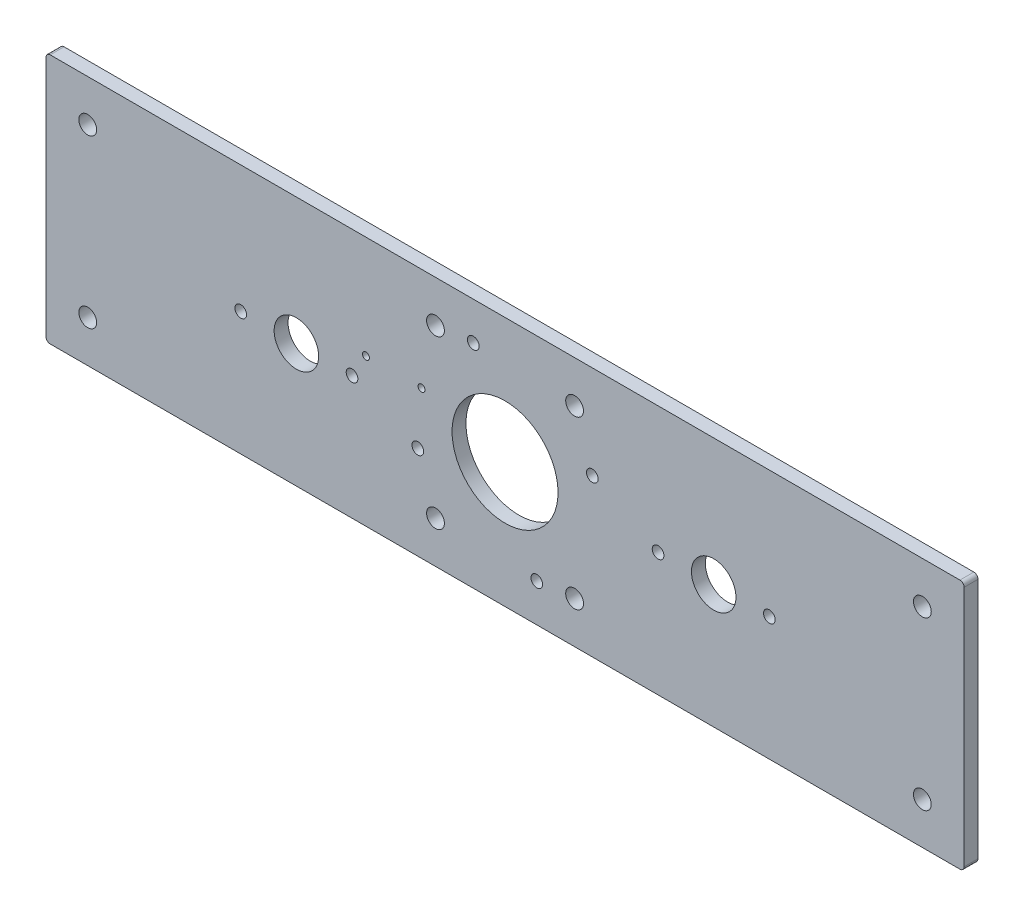
from build123d import *

# Parameters (mm, degrees)
SKETCH1_W             = 330
SKETCH1_H             = 90
SKETCH1_R             = 19.05
BOSS_EXTRUDE1_DEPTH   = 2.5
M6_CLEARANCE_HOLE1_D  = 6.4
SKETCH3_R             = 8
CUT_EXTRUDE2_DEPTH    = 6
M5X0_8_TAPPED_HOLE1_D = 4.2
M5X0_8_TAPPED_HOLE3_D = 4.2
FILLET1_R             = 1.5
M3X0_5_TAPPED_HOLE1_D = 2.5


with BuildPart() as part:
    # Sketch1 → Boss-Extrude1 (new body, symmetric)
    with BuildSketch(Plane.XY):
        Rectangle(SKETCH1_W, SKETCH1_H)
        Circle(SKETCH1_R, mode=Mode.SUBTRACT)
    extrude(amount=BOSS_EXTRUDE1_DEPTH, both=True)

    # M6 Clearance Hole1 (through all)
    with Locations(Plane.XY.offset(2.5)):
        with Locations((-150, 30), (-25, 30), (-25, -30), (-150, -30)):
            m6_clearance_hole1 = Hole(M6_CLEARANCE_HOLE1_D / 2)

    # Mirror2: M6 Clearance Hole1 across plane
    add(m6_clearance_hole1.mirror(Plane(origin=(0, 0, 0), x_dir=(0, 0, 1), z_dir=(1, 0, 0))), mode=Mode.SUBTRACT)

    # Sketch3 → Cut-Extrude2 (cut, through all)
    with BuildSketch(Plane.XY.offset(2.5)):
        with Locations((-75, -0.6)):
            Circle(SKETCH3_R)
    cut_extrude2 = extrude(amount=-CUT_EXTRUDE2_DEPTH, mode=Mode.SUBTRACT)

    # M5x0.8 Tapped Hole1 (through all)
    with Locations(Plane.XY.offset(2.5)):
        with Locations((-95, -0.6), (-55, -0.6)):
            m5x0_8_tapped_hole1 = Hole(M5X0_8_TAPPED_HOLE1_D / 2)

    # Mirror1: Cut-Extrude2, M5x0.8 Tapped Hole1 across plane
    add(cut_extrude2.mirror(Plane(origin=(0, 0, 0), x_dir=(0, 0, 1), z_dir=(1, 0, 0))), mode=Mode.SUBTRACT)
    add(m5x0_8_tapped_hole1.mirror(Plane(origin=(0, 0, 0), x_dir=(0, 0, 1), z_dir=(1, 0, 0))), mode=Mode.SUBTRACT)

    # M5x0.8 Tapped Hole3 (through all)
    with Locations(Plane.XY.offset(2.5)):
        with Locations((-11.415072797, 31.362654751), (11.415072797, -31.362654751), (-31.362654751, -11.415072797), (31.362654751, 11.415072797)):
            Hole(M5X0_8_TAPPED_HOLE3_D / 2)

    # Fillet1
    fillet1_edges = [part.edges().sort_by_distance(p)[0] for p in [
        (-165, 45, 0),
        (165, 45, 0),
        (165, -45, 0),
        (-165, -45, 0),
    ]]
    fillet(fillet1_edges, radius=FILLET1_R)

    # M3x0.5 Tapped Hole1 (through all)
    with Locations(Plane.XY.offset(2.5)):
        with Locations((-50, 8), (-30, 8)):
            Hole(M3X0_5_TAPPED_HOLE1_D / 2)


solid = part.part
